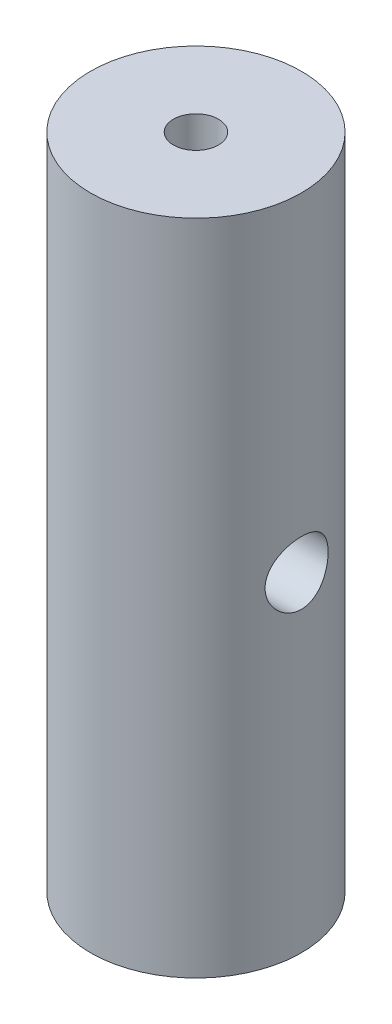
from build123d import *

# Parameters (mm, degrees)
EXTRUDE1_DEPTH                 = 19.812
EXTRUDE1_DEPTH_BACK            = 19.812
SKETCH1_R                      = 6.35
SKETCH1_R_2                    = 1.35255
CUT_EXTRUDE1_REACH             = 23.752
SKETCH3_R                      = 1.89865
CUT_EXTRUDE1_DIRECTION_2_REACH = 23.752


with BuildPart() as part:
    # Sketch1 → Extrude1 (new, two sides: drawn at the far end of the back side and taken through both)
    with BuildSketch(Plane(origin=(0, 0, 0), x_dir=(1, 0, 0), z_dir=(0, 1, 0)).offset(-EXTRUDE1_DEPTH_BACK)):
        Circle(SKETCH1_R)
        Circle(SKETCH1_R_2, mode=Mode.SUBTRACT)
    extrude(amount=EXTRUDE1_DEPTH + EXTRUDE1_DEPTH_BACK)

    # Sketch3 → Cut-Extrude1 (cut, up to next)
    with BuildSketch(Plane(origin=(0, 0, 0), x_dir=(0, 0, -1), z_dir=(1, 0, 0)), mode=Mode.PRIVATE) as cut_extrude1_sk1:
        Circle(SKETCH3_R)
    cut_extrude1_tool1 = extrude(cut_extrude1_sk1.sketch, amount=-CUT_EXTRUDE1_REACH, mode=Mode.PRIVATE) & part.part
    add(cut_extrude1_tool1.solids().sort_by_distance((0, 0, 0))[0], mode=Mode.SUBTRACT)

    # Sketch3 → Cut-Extrude1 direction 2 (cut, up to next)
    with BuildSketch(Plane(origin=(0, 0, 0), x_dir=(0, 0, -1), z_dir=(1, 0, 0)), mode=Mode.PRIVATE) as cut_extrude1_direction_2_sk1:
        Circle(SKETCH3_R)
    cut_extrude1_direction_2_tool1 = extrude(cut_extrude1_direction_2_sk1.sketch, amount=CUT_EXTRUDE1_DIRECTION_2_REACH, mode=Mode.PRIVATE) & part.part
    add(cut_extrude1_direction_2_tool1.solids().sort_by_distance((0, 0, 0))[0], mode=Mode.SUBTRACT)


solid = part.part
